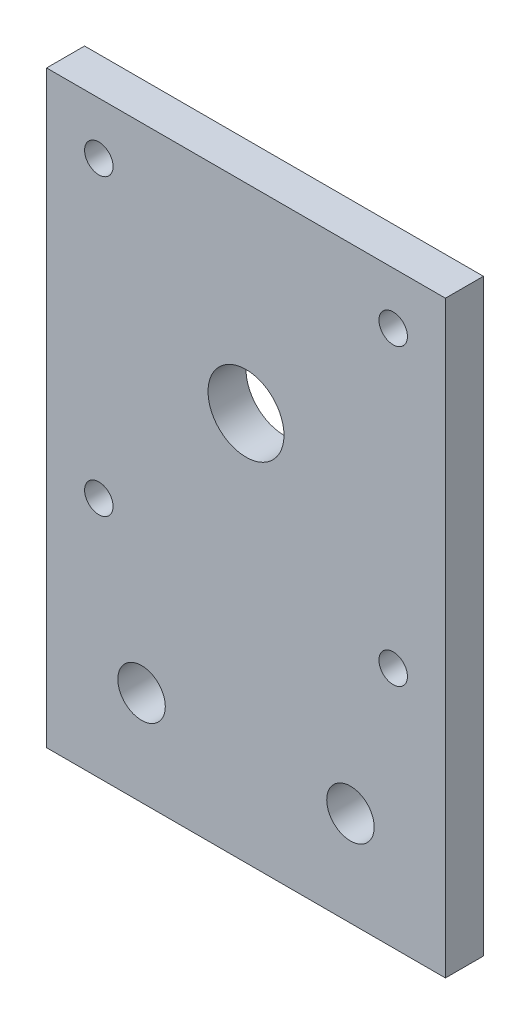
from build123d import *

# Parameters (mm, degrees)
SKETCH1_W           = 42
SKETCH1_H           = 42
SKETCH1_R           = 4
SKETCH1_R_2         = 1.5
BOSS_EXTRUDE1_DEPTH = 4
SKETCH3_W           = 42
SKETCH3_H           = 4
BOSS_EXTRUDE2_DEPTH = 20
SKETCH4_R           = 2.5
CUT_EXTRUDE2_DEPTH  = 20


with BuildPart() as part:
    # Sketch1 → Boss-Extrude1 (new body)
    with BuildSketch(Plane.XY):
        Rectangle(SKETCH1_W, SKETCH1_H)
        Circle(SKETCH1_R, mode=Mode.SUBTRACT)
        with Locations((-15.5, 15.5)):
            Circle(SKETCH1_R_2, mode=Mode.SUBTRACT)
        with Locations((15.5, 15.5)):
            Circle(SKETCH1_R_2, mode=Mode.SUBTRACT)
        with Locations((15.5, -15.5)):
            Circle(SKETCH1_R_2, mode=Mode.SUBTRACT)
        with Locations((-15.5, -15.5)):
            Circle(SKETCH1_R_2, mode=Mode.SUBTRACT)
    extrude(amount=BOSS_EXTRUDE1_DEPTH)

    # Sketch3 → Boss-Extrude2 (add)
    with BuildSketch(Plane.XZ.offset(21)):
        with Locations((0, 2)):
            Rectangle(SKETCH3_W, SKETCH3_H)
    extrude(amount=BOSS_EXTRUDE2_DEPTH)

    # Sketch4 → Cut-Extrude2 (cut)
    with BuildSketch(Plane(origin=(0, 0, 0), x_dir=(-1, 0, 0), z_dir=(0, 0, -1))):
        with Locations((-11, -31)):
            Circle(SKETCH4_R)
        with Locations((11, -31)):
            Circle(SKETCH4_R)
    extrude(amount=-CUT_EXTRUDE2_DEPTH, mode=Mode.SUBTRACT)


solid = part.part
